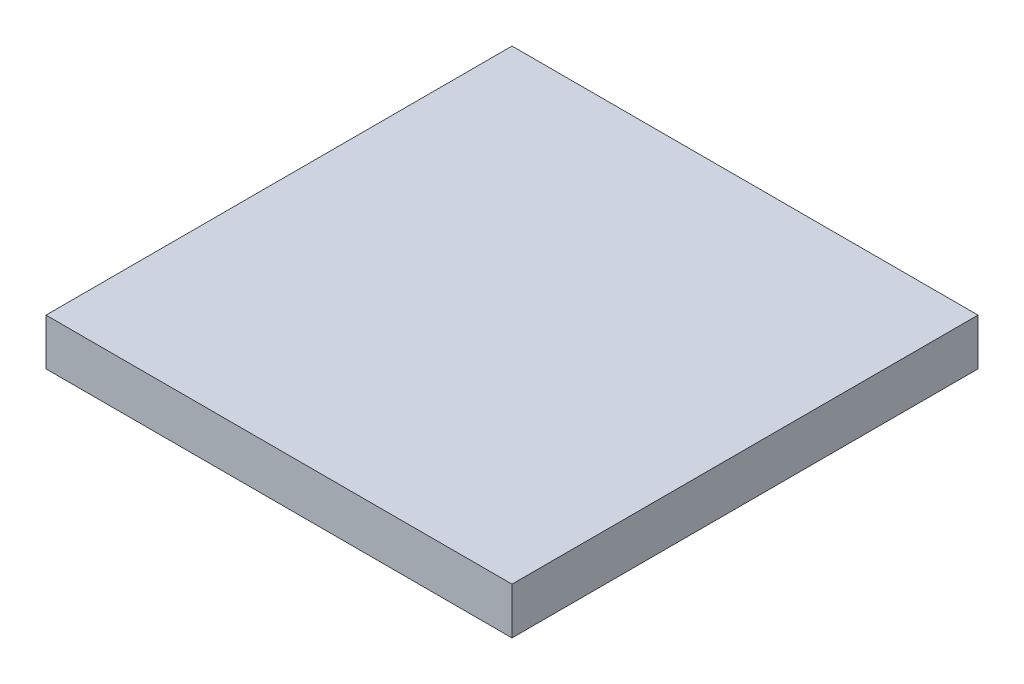
from build123d import *

# Parameters (mm, degrees)
BOSS_EXTRUDE1_DEPTH = 10
SKETCH2_R           = 1
CUT_EXTRUDE1_DEPTH  = 0.0001


with BuildPart() as part:
    # Sketch1 → Boss-Extrude1 (new body)
    with BuildSketch(Plane(origin=(0, 0, 0), x_dir=(1, 0, 0), z_dir=(0, 1, 0))):
        Polygon((-50, 0), (-50, 35), (50, 35), (50, 0), (50, -65), (-50, -65), align=None)
    extrude(amount=BOSS_EXTRUDE1_DEPTH)

    # Sketch2 → Cut-Extrude1 (cut)
    with BuildSketch(Plane(origin=(0, 0, 0), x_dir=(1, 0, 0), z_dir=(0, 1, 0))):
        Circle(SKETCH2_R)
    extrude(amount=CUT_EXTRUDE1_DEPTH, mode=Mode.SUBTRACT)


solid = part.part
